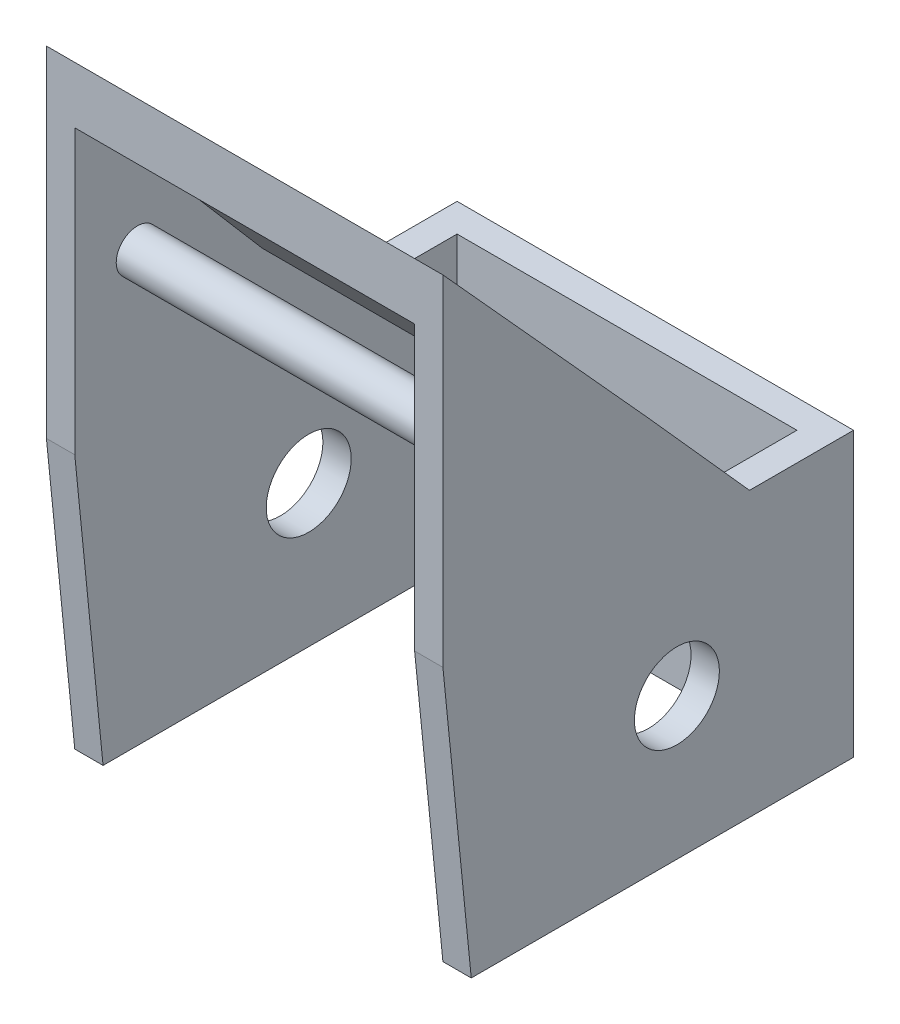
from build123d import *

# Parameters (mm, degrees)
SKETCH1_W            = 140
SKETCH1_H            = 100
BOSS_EXTRUDE1_DEPTH  = 10
SKETCH2_W            = 10
SKETCH2_H            = 100
BOSS_EXTRUDE2_DEPTH  = 120
BOSS_EXTRUDE3_DEPTH  = 10
BOSS_EXTRUDE4_DEPTH  = 10
BOSS_EXTRUDE6_DEPTH  = 140
SKETCH7_W            = 120
SKETCH7_H            = 98.500973615
CUT_EXTRUDE1_DEPTH   = 30
SKETCH8_R            = 15
CUT_EXTRUDE2_DEPTH   = 170
SKETCH9_R            = 15
CUT_EXTRUDE3_DEPTH   = 170
CUT_EXTRUDE4_DEPTH   = 140
SKETCH14_W           = 120
SKETCH14_H           = 70
CUT_EXTRUDE5_DEPTH   = 10
BOSS_EXTRUDE8_DEPTH  = 10
BOSS_EXTRUDE9_DEPTH  = 10
SKETCH17_R           = 7.5
BOSS_EXTRUDE10_DEPTH = 120


with BuildPart() as part:
    # Sketch1 → Boss-Extrude1 (new body)
    with BuildSketch(Plane.XY):
        Rectangle(SKETCH1_W, SKETCH1_H)
    extrude(amount=BOSS_EXTRUDE1_DEPTH)

    # Sketch2 → Boss-Extrude2 (add)
    with BuildSketch(Plane.XY.offset(10)):
        with Locations((65, 0)):
            Rectangle(SKETCH2_W, SKETCH2_H)
        with Locations((-65, 0)):
            Rectangle(SKETCH2_W, SKETCH2_H)
    extrude(amount=BOSS_EXTRUDE2_DEPTH)

    # Sketch3 → Boss-Extrude3 (add)
    with BuildSketch(Plane.ZY.offset(70)):
        Polygon((130, 50), (145, 50), (135, -50), (130, -50), align=None)
    extrude(amount=-BOSS_EXTRUDE3_DEPTH)

    # Sketch4 → Boss-Extrude4 (add)
    with BuildSketch(Plane(origin=(70, 0, 0), x_dir=(0, 0, -1), z_dir=(1, 0, 0))):
        Polygon((-130, 50), (-145, 50), (-135, -50), (-130, -50), align=None)
    extrude(amount=-BOSS_EXTRUDE4_DEPTH)

    # Sketch6 → Boss-Extrude6 (add)
    with BuildSketch(Plane.ZY.offset(70)):
        Polygon((72.5, 90), (145, 170), (145, 50), (72.5, 50), (36.751913988, 50), align=None)
    extrude(amount=-BOSS_EXTRUDE6_DEPTH)

    # Sketch7 → Cut-Extrude1 (cut)
    with BuildSketch(Plane.XZ.offset(-50)):
        with Locations((0, 95.749513193)):
            Rectangle(SKETCH7_W, SKETCH7_H)
    extrude(amount=-CUT_EXTRUDE1_DEPTH, mode=Mode.SUBTRACT)

    # Sketch8 → Cut-Extrude2 (cut)
    with BuildSketch(Plane.ZY.offset(70)):
        with Locations((62.387439839, 0)):
            Circle(SKETCH8_R)
    extrude(amount=-CUT_EXTRUDE2_DEPTH, mode=Mode.SUBTRACT)

    # Sketch9 → Cut-Extrude3 (cut)
    with BuildSketch(Plane.XY.offset(10)):
        Circle(SKETCH9_R)
    extrude(amount=-CUT_EXTRUDE3_DEPTH, mode=Mode.SUBTRACT)

    # Sketch13 → Cut-Extrude4 (cut)
    with BuildSketch(Plane.ZY.offset(70)):
        Polygon((70.157530745, 70), (136.03947853, 146.817766748), (136.03947853, 70), align=None)
    extrude(amount=-CUT_EXTRUDE4_DEPTH, mode=Mode.SUBTRACT)

    # Sketch14 → Cut-Extrude5 (cut)
    with BuildSketch(Plane.XY.offset(145)):
        with Locations((0, 115)):
            Rectangle(SKETCH14_W, SKETCH14_H)
    extrude(amount=-CUT_EXTRUDE5_DEPTH, mode=Mode.SUBTRACT)

    # Sketch15 → Boss-Extrude8 (add)
    with BuildSketch(Plane.ZY.offset(70)):
        Polygon((136.03947853, 146.817766748), (136.03947853, 70), (70.157530745, 70), align=None)
    extrude(amount=-BOSS_EXTRUDE8_DEPTH)

    # Sketch16 → Boss-Extrude9 (add)
    with BuildSketch(Plane(origin=(70, 0, 0), x_dir=(0, 0, -1), z_dir=(1, 0, 0))):
        Polygon((-136.03947853, 146.817766748), (-136.03947853, 70), (-70.157530745, 70), align=None)
    extrude(amount=-BOSS_EXTRUDE9_DEPTH)

    # Sketch17 → Boss-Extrude10 (add)
    with BuildSketch(Plane.ZY.offset(-60)):
        with Locations((122.863088973, 101.43242494)):
            Circle(SKETCH17_R)
    extrude(amount=BOSS_EXTRUDE10_DEPTH)


solid = part.part
